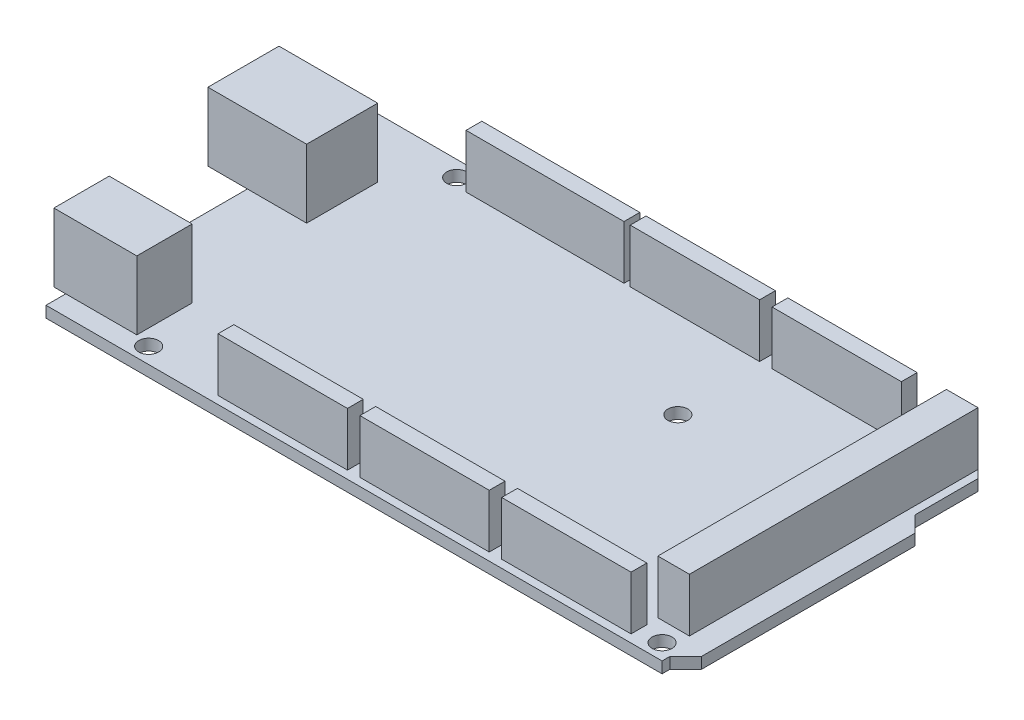
from build123d import *

# Parameters (mm, degrees)
BOSS_EXTRUDE1_DEPTH = 1.8
CUT_EXTRUDE1_REACH  = 3.8
SKETCH2_R           = 1.6
SKETCH3_W           = 15.875
SKETCH3_H           = 11.43
BOSS_EXTRUDE2_DEPTH = 11
SKETCH4_W           = 13.335
SKETCH4_H           = 8.89
BOSS_EXTRUDE3_DEPTH = 11
SKETCH5_W           = 20.8
SKETCH5_H           = 2.54
SKETCH5_W_2         = 5.08
SKETCH5_H_2         = 46.4
SKETCH5_W_3         = 25.4
BOSS_EXTRUDE4_DEPTH = 8.6


with BuildPart() as part:
    # Sketch1 → Boss-Extrude1 (new body)
    with BuildSketch(Plane(origin=(0, 0, 0), x_dir=(1, 0, 0), z_dir=(0, 1, 0))):
        Polygon((-49.53, -26.67), (49.53, -26.67), (49.53, -25.4), (52.07, -22.86), (52.07, 11.43), (49.53, 13.97), (49.53, 24.13), (46.99, 26.67), (-49.53, 26.67), align=None)
    extrude(amount=BOSS_EXTRUDE1_DEPTH)

    # Sketch2 → Cut-Extrude1 (cut, up to next)
    with BuildSketch(Plane(origin=(0, 1.8, 0), x_dir=(1, 0, 0), z_dir=(0, 1, 0)), mode=Mode.PRIVATE) as cut_extrude1_sk1:
        with Locations((-35.56, -24.13)):
            Circle(SKETCH2_R)
    cut_extrude1_tool1 = extrude(cut_extrude1_sk1.sketch, amount=-CUT_EXTRUDE1_REACH, mode=Mode.PRIVATE) & part.part
    add(cut_extrude1_tool1.solids().sort_by_distance((-35.56, 1.8, 24.13))[0], mode=Mode.SUBTRACT)
    # Sketch2 → Cut-Extrude1 (cut, up to next)
    with BuildSketch(Plane(origin=(0, 1.8, 0), x_dir=(1, 0, 0), z_dir=(0, 1, 0)), mode=Mode.PRIVATE) as cut_extrude1_sk2:
        with Locations((16.51, -19.05)):
            Circle(SKETCH2_R)
    cut_extrude1_tool2 = extrude(cut_extrude1_sk2.sketch, amount=-CUT_EXTRUDE1_REACH, mode=Mode.PRIVATE) & part.part
    add(cut_extrude1_tool2.solids().sort_by_distance((16.51, 1.8, 19.05))[0], mode=Mode.SUBTRACT)
    # Sketch2 → Cut-Extrude1 (cut, up to next)
    with BuildSketch(Plane(origin=(0, 1.8, 0), x_dir=(1, 0, 0), z_dir=(0, 1, 0)), mode=Mode.PRIVATE) as cut_extrude1_sk3:
        with Locations((16.51, 8.89)):
            Circle(SKETCH2_R)
    cut_extrude1_tool3 = extrude(cut_extrude1_sk3.sketch, amount=-CUT_EXTRUDE1_REACH, mode=Mode.PRIVATE) & part.part
    add(cut_extrude1_tool3.solids().sort_by_distance((16.51, 1.8, -8.89))[0], mode=Mode.SUBTRACT)
    # Sketch2 → Cut-Extrude1 (cut, up to next)
    with BuildSketch(Plane(origin=(0, 1.8, 0), x_dir=(1, 0, 0), z_dir=(0, 1, 0)), mode=Mode.PRIVATE) as cut_extrude1_sk4:
        with Locations((46.99, -24.13)):
            Circle(SKETCH2_R)
    cut_extrude1_tool4 = extrude(cut_extrude1_sk4.sketch, amount=-CUT_EXTRUDE1_REACH, mode=Mode.PRIVATE) & part.part
    add(cut_extrude1_tool4.solids().sort_by_distance((46.99, 1.8, 24.13))[0], mode=Mode.SUBTRACT)
    # Sketch2 → Cut-Extrude1 (cut, up to next)
    with BuildSketch(Plane(origin=(0, 1.8, 0), x_dir=(1, 0, 0), z_dir=(0, 1, 0)), mode=Mode.PRIVATE) as cut_extrude1_sk5:
        with Locations((40.64, 24.13)):
            Circle(SKETCH2_R)
    cut_extrude1_tool5 = extrude(cut_extrude1_sk5.sketch, amount=-CUT_EXTRUDE1_REACH, mode=Mode.PRIVATE) & part.part
    add(cut_extrude1_tool5.solids().sort_by_distance((40.64, 1.8, -24.13))[0], mode=Mode.SUBTRACT)
    # Sketch2 → Cut-Extrude1 (cut, up to next)
    with BuildSketch(Plane(origin=(0, 1.8, 0), x_dir=(1, 0, 0), z_dir=(0, 1, 0)), mode=Mode.PRIVATE) as cut_extrude1_sk6:
        with Locations((-34.29, 24.13)):
            Circle(SKETCH2_R)
    cut_extrude1_tool6 = extrude(cut_extrude1_sk6.sketch, amount=-CUT_EXTRUDE1_REACH, mode=Mode.PRIVATE) & part.part
    add(cut_extrude1_tool6.solids().sort_by_distance((-34.29, 1.8, -24.13))[0], mode=Mode.SUBTRACT)

    # Sketch3 → Boss-Extrude2 (add)
    with BuildSketch(Plane(origin=(0, 1.8, 0), x_dir=(1, 0, 0), z_dir=(0, 1, 0))):
        with Locations((-47.9425, 11.43)):
            Rectangle(SKETCH3_W, SKETCH3_H)
    extrude(amount=BOSS_EXTRUDE2_DEPTH)

    # Sketch4 → Boss-Extrude3 (add)
    with BuildSketch(Plane(origin=(0, 1.8, 0), x_dir=(1, 0, 0), z_dir=(0, 1, 0))):
        with Locations((-44.7675, -19.05)):
            Rectangle(SKETCH4_W, SKETCH4_H)
    extrude(amount=BOSS_EXTRUDE3_DEPTH)

    # Sketch5 → Boss-Extrude4 (add)
    with BuildSketch(Plane(origin=(0, 1.8, 0), x_dir=(1, 0, 0), z_dir=(0, 1, 0))):
        with Locations((-12.73, -24.13)):
            Rectangle(SKETCH5_W, SKETCH5_H)
        with Locations((10.07, -24.13)):
            Rectangle(SKETCH5_W, SKETCH5_H)
        with Locations((32.87, -24.13)):
            Rectangle(SKETCH5_W, SKETCH5_H)
        with Locations((45.72, 2.2)):
            Rectangle(SKETCH5_W_2, SKETCH5_H_2)
        with Locations((28.08, 24.13)):
            Rectangle(SKETCH5_W, SKETCH5_H)
        with Locations((5.28, 24.13)):
            Rectangle(SKETCH5_W, SKETCH5_H)
        with Locations((-18.82, 24.13)):
            Rectangle(SKETCH5_W_3, SKETCH5_H)
    extrude(amount=BOSS_EXTRUDE4_DEPTH)


solid = part.part
